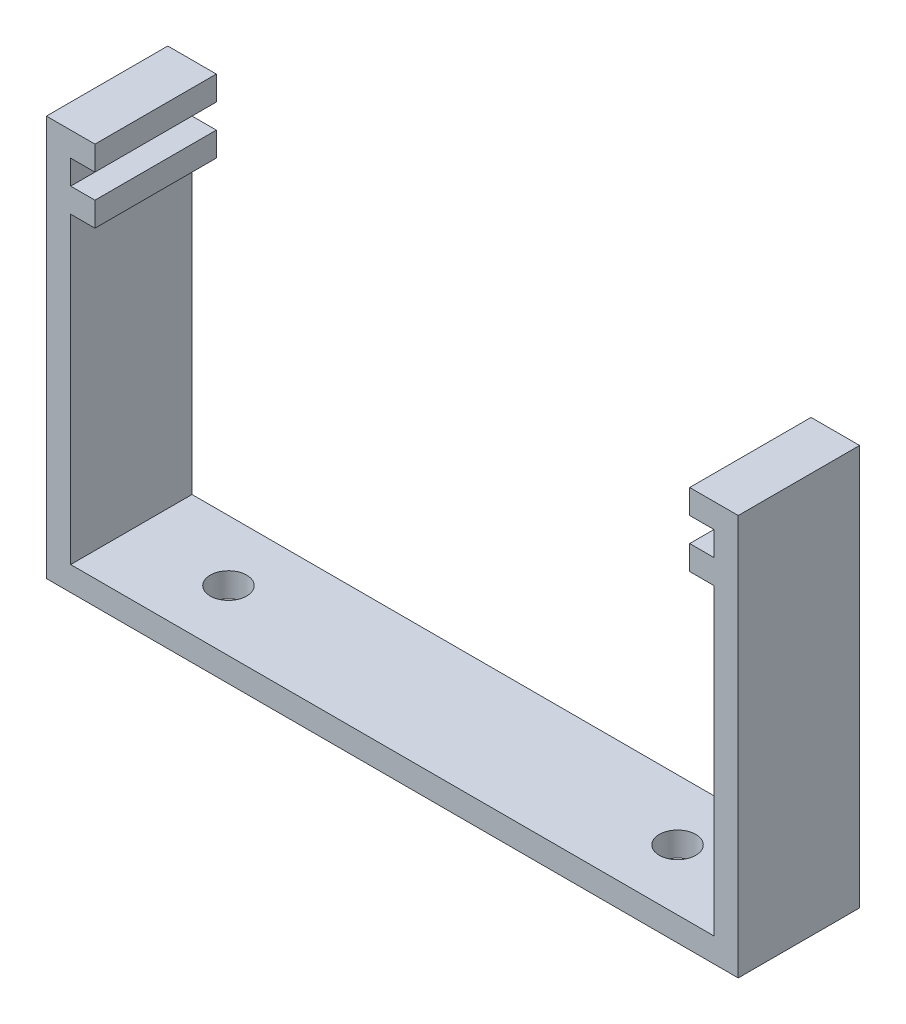
from build123d import *

# Parameters (mm, degrees)
SALIENTE_EXTRUIR1_DEPTH = 10
CROQUIS2_R              = 1.5
CORTAR_EXTRUIR1_DEPTH   = 10


with BuildPart() as part:
    # Croquis1 → Saliente-Extruir1 (new body)
    with BuildSketch(Plane.XY):
        Polygon((0, 0), (53, 0), (53, 25), (51, 25), (51, 27), (53, 27), (53, 29), (51, 29), (51, 31), (55, 31), (55, -2), (-2, -2), (-2, 31), (2, 31), (2, 29), (0, 29), (0, 27), (2, 27), (2, 25), (0, 25), align=None)
    extrude(amount=SALIENTE_EXTRUIR1_DEPTH)

    # Croquis2 → Cortar-Extruir1 (cut)
    with BuildSketch(Plane.XZ.offset(2)):
        with Locations((45, 5)):
            Circle(CROQUIS2_R)
        with Locations((8, 5)):
            Circle(CROQUIS2_R)
    extrude(amount=-CORTAR_EXTRUIR1_DEPTH, mode=Mode.SUBTRACT)


solid = part.part
